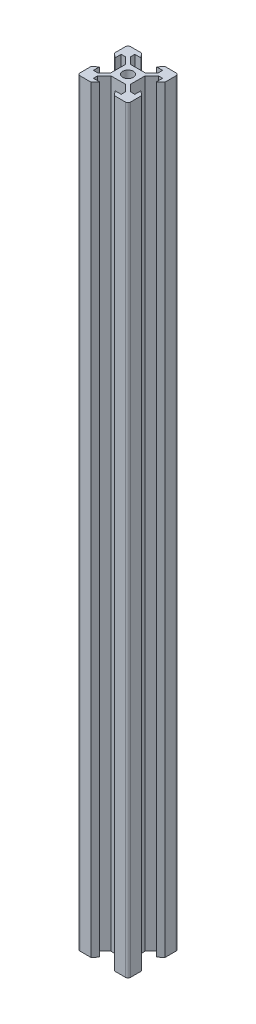
from build123d import *

# Parameters (mm, degrees)
SKETCH1_R           = 2.1
BOSS_EXTRUDE1_DEPTH = 300


with BuildPart() as part:
    # Sketch1 → Boss-Extrude1 (new body)
    with BuildSketch(Plane(origin=(0, 0, 0), x_dir=(1, 0, 0), z_dir=(0, 1, 0))):
        with BuildLine():
            Line((-5.5, 8.2), (-3.125, 8.2))
            Line((-3.125, 8.2), (-4.58, 10))
            Line((-4.58, 10), (-9, 10))
            ThreePointArc((-9, 10), (-9.707106781, 9.707106781), (-10, 9))
            Line((-10, 9), (-10, 4.58))
            Line((-10, 4.58), (-8.2, 3.125))
            Line((-8.2, 3.125), (-8.2, 5.5))
            Line((-8.2, 5.5), (-6.56, 5.5))
            Line((-6.56, 5.5), (-3.9, 2.84))
            Line((-3.9, 2.84), (-3.9, -2.84))
            Line((-3.9, -2.84), (-6.56, -5.5))
            Line((-6.56, -5.5), (-8.2, -5.5))
            Line((-8.2, -5.5), (-8.2, -3.125))
            Line((-8.2, -3.125), (-10, -4.58))
            Line((-10, -4.58), (-10, -9))
            ThreePointArc((-10, -9), (-9.707106781, -9.707106781), (-9, -10))
            Line((-9, -10), (-4.58, -10))
            Line((-4.58, -10), (-3.125, -8.2))
            Line((-3.125, -8.2), (-5.5, -8.2))
            Line((-5.5, -8.2), (-5.5, -6.56))
            Line((-5.5, -6.56), (-2.84, -3.9))
            Line((-2.84, -3.9), (2.84, -3.9))
            Line((2.84, -3.9), (5.5, -6.56))
            Line((5.5, -6.56), (5.5, -8.2))
            Line((5.5, -8.2), (3.125, -8.2))
            Line((3.125, -8.2), (4.58, -10))
            Line((4.58, -10), (9, -10))
            ThreePointArc((9, -10), (9.707106781, -9.707106781), (10, -9))
            Line((10, -9), (10, -4.58))
            Line((10, -4.58), (8.2, -3.125))
            Line((8.2, -3.125), (8.2, -5.5))
            Line((8.2, -5.5), (6.56, -5.5))
            Line((6.56, -5.5), (3.9, -2.84))
            Line((3.9, -2.84), (3.9, 2.84))
            Line((3.9, 2.84), (6.56, 5.5))
            Line((6.56, 5.5), (8.2, 5.5))
            Line((8.2, 5.5), (8.2, 3.125))
            Line((8.2, 3.125), (10, 4.58))
            Line((10, 4.58), (10, 9))
            ThreePointArc((10, 9), (9.707106781, 9.707106781), (9, 10))
            Line((9, 10), (4.58, 10))
            Line((4.58, 10), (3.125, 8.2))
            Line((3.125, 8.2), (5.5, 8.2))
            Line((5.5, 8.2), (5.5, 6.56))
            Line((5.5, 6.56), (2.84, 3.9))
            Line((2.84, 3.9), (-2.84, 3.9))
            Line((-2.84, 3.9), (-5.5, 6.56))
            Line((-5.5, 6.56), (-5.5, 8.2))
        make_face()
        Circle(SKETCH1_R, mode=Mode.SUBTRACT)
    extrude(amount=BOSS_EXTRUDE1_DEPTH)


solid = part.part
